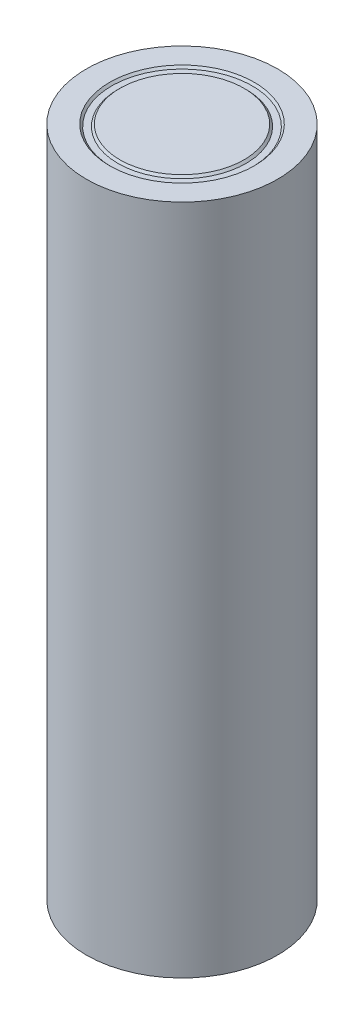
from build123d import *

# Parameters (mm, degrees)
SKETCH1_R           = 9.25
BOSS_EXTRUDE1_DEPTH = 65
SKETCH2_R           = 7
SKETCH2_R_2         = 6
CUT_EXTRUDE1_DEPTH  = 0.2
CUT_EXTRUDE1_TAPER  = 45


with BuildPart() as part:
    # Sketch1 → Boss-Extrude1 (new body)
    with BuildSketch(Plane(origin=(0, 0, 0), x_dir=(1, 0, 0), z_dir=(0, 1, 0))):
        Circle(SKETCH1_R)
    extrude(amount=BOSS_EXTRUDE1_DEPTH)

    # Sketch2 → Cut-Extrude1 (cut)
    with BuildSketch(Plane(origin=(0, 65, 0), x_dir=(1, 0, 0), z_dir=(0, 1, 0))):
        Circle(SKETCH2_R)
        Circle(SKETCH2_R_2, mode=Mode.SUBTRACT)
    extrude(amount=-CUT_EXTRUDE1_DEPTH, taper=CUT_EXTRUDE1_TAPER, mode=Mode.SUBTRACT)


solid = part.part
